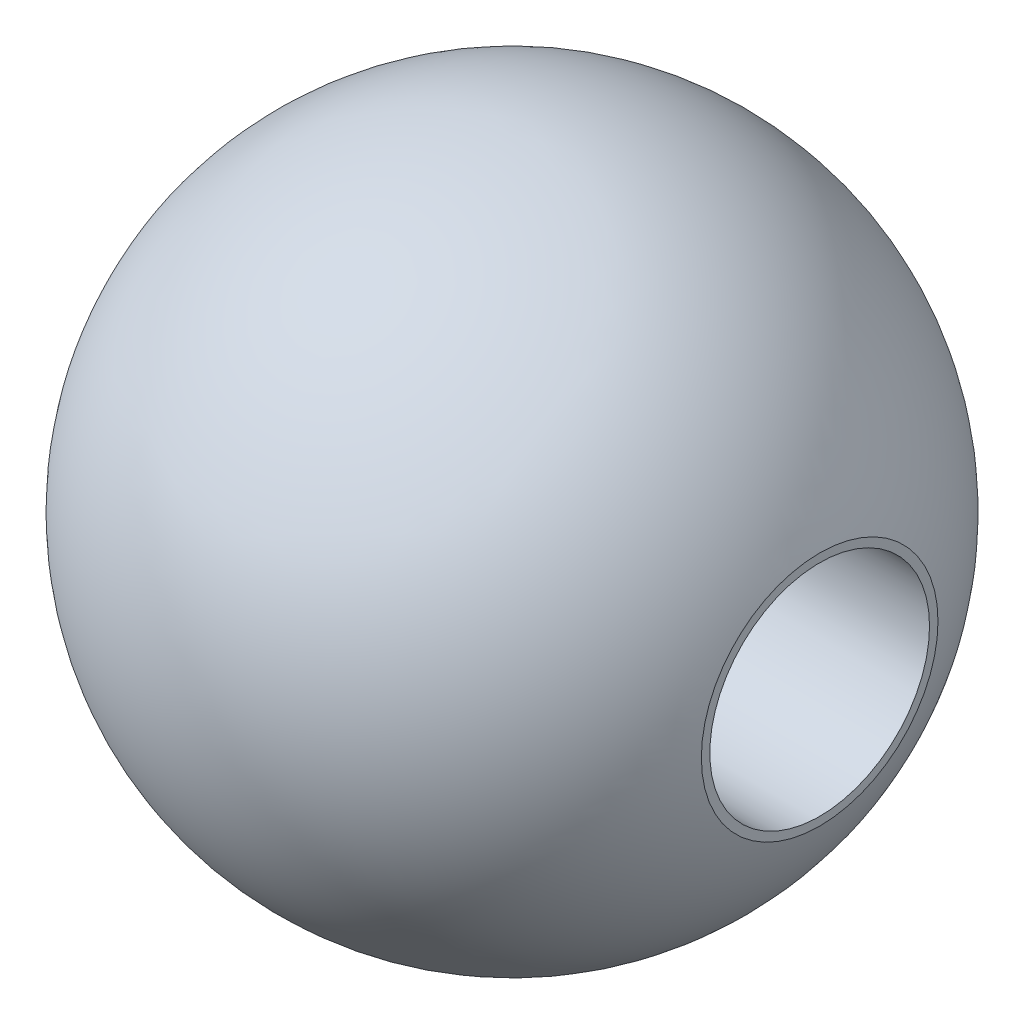
from build123d import *

# Parameters (mm, degrees)
SKETCH2_R          = 5
CUT_EXTRUDE1_DEPTH = 29


with BuildPart() as part:
    # Sketch1 → Revolve1 (revolve)
    with BuildSketch(Plane(origin=(0, 0, 0), x_dir=(1, 0, 0), z_dir=(0, 1, 0))):
        with BuildLine():
            Line((-14, 0), (-14, 5.385164807))
            ThreePointArc((-14, 5.385164807), (0, 15), (14, 5.385164807))
            Line((14, 5.385164807), (14, 0))
            Line((14, 0), (-14, 0))
        make_face()
    revolve(axis=Axis((-14, 0, 0), (1, 0, 0)))

    # Sketch2 → Cut-Extrude1 (cut, through all)
    with BuildSketch(Plane(origin=(14, 0, 0), x_dir=(0, 0, -1), z_dir=(1, 0, 0))):
        Circle(SKETCH2_R)
    extrude(amount=-CUT_EXTRUDE1_DEPTH, mode=Mode.SUBTRACT)


solid = part.part
